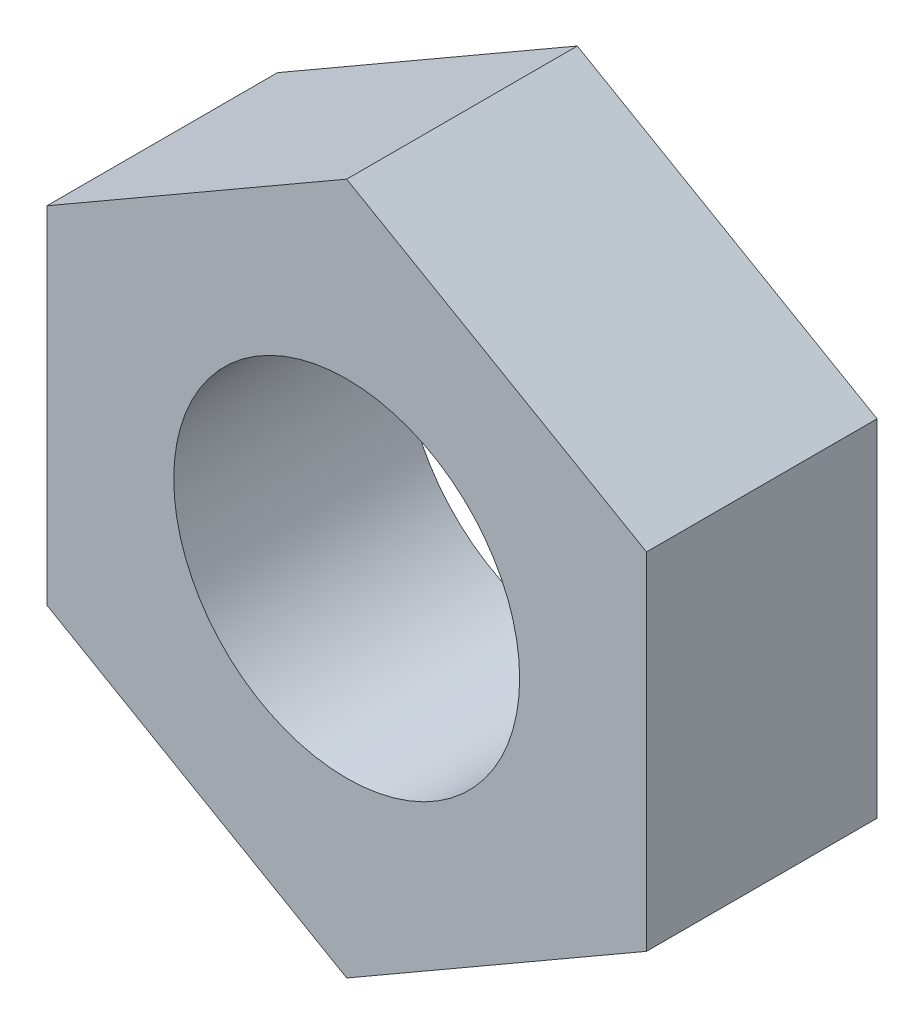
from build123d import *

# Parameters (mm, degrees)
CROQUIS1_R              = 3
SALIENTE_EXTRUIR1_DEPTH = 4


with BuildPart() as part:
    # Croquis1 → Saliente-Extruir1 (new body)
    with BuildSketch(Plane.XY):
        Polygon((5.2, 3), (5.2, 9), (0, 12), (-5.2, 9), (-5.2, 3), (0, 0), align=None)
        with Locations((0, 6)):
            Circle(CROQUIS1_R, mode=Mode.SUBTRACT)
    extrude(amount=SALIENTE_EXTRUIR1_DEPTH)


solid = part.part
